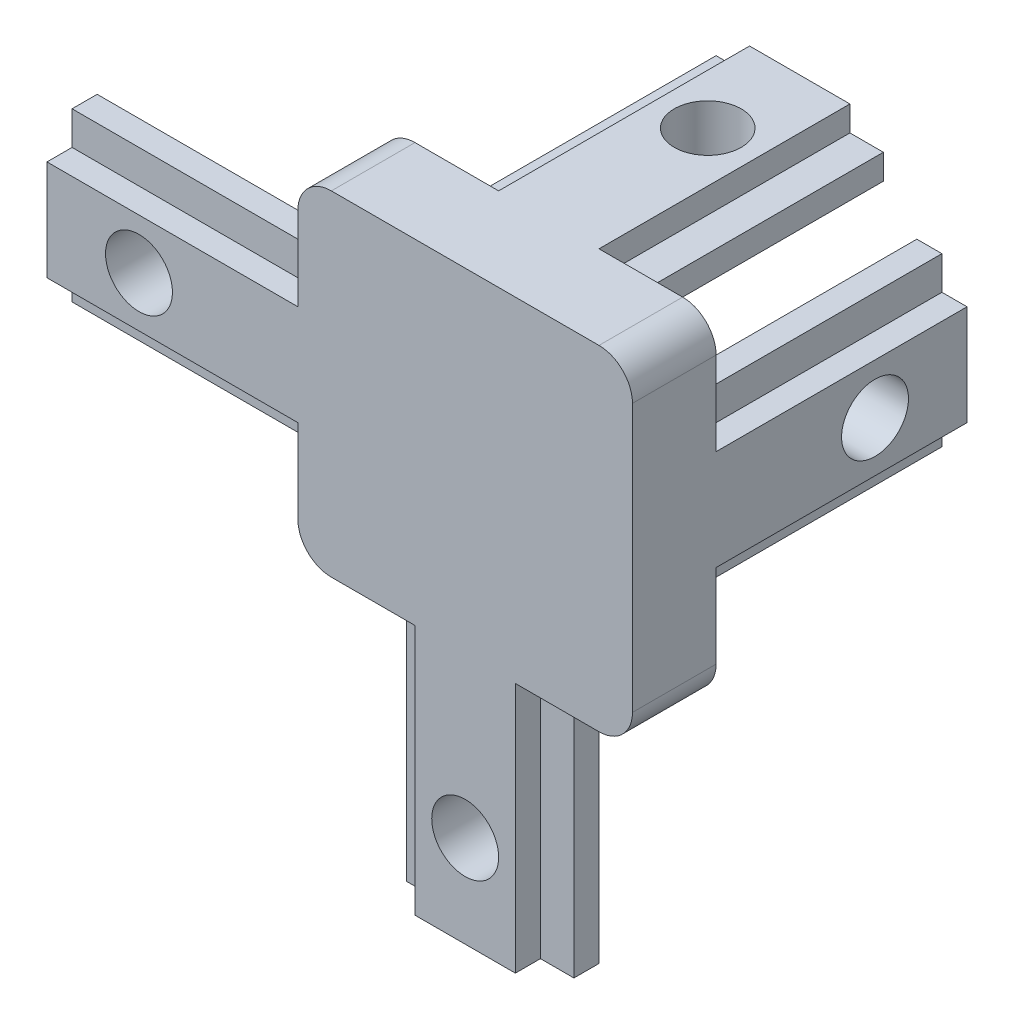
from build123d import *

# Parameters (mm, degrees)
SKETCH1_W                 = 35.000000224
SKETCH1_H                 = 10
BOSS_EXTRUDE1_DEPTH       = 5
CUT_EXTRUDE1_DEPTH        = 15.000000224
SKETCH3_W                 = 20
SKETCH3_H                 = 5
BOSS_EXTRUDE2_DEPTH       = 5
CUT_EXTRUDE2_DEPTH        = 15.000000224
SKETCH5_W                 = 20
SKETCH5_H                 = 5
BOSS_EXTRUDE3_DEPTH       = 5
BOSS_EXTRUDE4_DEPTH       = 15
BOSS_EXTRUDE5_DEPTH       = 15
BOSS_EXTRUDE6_DEPTH       = 15
CUT_EXTRUDE3_DEPTH        = 1
SKETCH10_W                = 15
SKETCH10_H                = 1.5
CUT_EXTRUDE4_DEPTH        = 2.000000104
SKETCH11_W                = 2.000000194
SKETCH11_H                = 1.5
CUT_EXTRUDE5_DEPTH        = 15
SKETCH12_W                = 1.5
SKETCH12_H                = 2
CUT_EXTRUDE6_DEPTH        = 15.000000224
SKETCH13_W                = 1.5
SKETCH13_H                = 2.000000104
CUT_EXTRUDE7_DEPTH        = 15.000000224
SKETCH14_W                = 1.999999806
SKETCH14_H                = 1.5
CUT_EXTRUDE8_DEPTH        = 15
SKETCH15_W                = 1.5
SKETCH15_H                = 15
CUT_EXTRUDE9_DEPTH        = 2.000000104
SKETCH16_W                = 1.5
SKETCH16_H                = 15
CUT_EXTRUDE10_DEPTH       = 2
SKETCH17_W                = 1.999999806
SKETCH17_H                = 1.5
CUT_EXTRUDE11_DEPTH       = 15
F_6_CLEARANCE_HOLE1_D     = 4
F_6_CLEARANCE_HOLE1_DEPTH = 5
F_6_CLEARANCE_HOLE2_D     = 4
F_6_CLEARANCE_HOLE2_DEPTH = 35
F_6_CLEARANCE_HOLE3_D     = 4
F_6_CLEARANCE_HOLE3_DEPTH = 35.000000224
FILLET1_R                 = 2


with BuildPart() as part:
    # Sketch1 → Boss-Extrude1 (new body)
    with BuildSketch(Plane(origin=(0, 0, -5), x_dir=(-1, 0, 0), z_dir=(0, 0, -1))):
        with Locations((-2.499999888, 10)):
            Rectangle(SKETCH1_W, SKETCH1_H)
    extrude(amount=-BOSS_EXTRUDE1_DEPTH)

    # Sketch2 → Cut-Extrude1 (cut)
    with BuildSketch(Plane.ZY.offset(15.000000224)):
        Polygon((-3, 5), (-5, 7), (-5, 5), align=None)
    extrude(amount=-CUT_EXTRUDE1_DEPTH, mode=Mode.SUBTRACT)

    # Sketch3 → Boss-Extrude2 (add)
    with BuildSketch(Plane.XZ.offset(-5)):
        with Locations((10, -2.5)):
            Rectangle(SKETCH3_W, SKETCH3_H)
    extrude(amount=BOSS_EXTRUDE2_DEPTH)

    # Sketch4 → Cut-Extrude2 (cut)
    with BuildSketch(Plane.ZY.offset(15.000000224)):
        Polygon((-5, 13), (-3, 15), (-5, 15), align=None)
    extrude(amount=-CUT_EXTRUDE2_DEPTH, mode=Mode.SUBTRACT)

    # Sketch5 → Boss-Extrude3 (add)
    with BuildSketch(Plane(origin=(0, 15, 0), x_dir=(-1, 0, 0), z_dir=(0, 1, 0))):
        with Locations((-10, -2.5)):
            Rectangle(SKETCH5_W, SKETCH5_H)
    extrude(amount=BOSS_EXTRUDE3_DEPTH)

    # Sketch6 → Boss-Extrude4 (add)
    with BuildSketch(Plane.XZ):
        Polygon((15, 0), (15, -3), (13, -5), (7, -5), (5, -3), (5, 0), align=None)
    extrude(amount=BOSS_EXTRUDE4_DEPTH)

    # Sketch7 → Boss-Extrude5 (add)
    with BuildSketch(Plane(origin=(0, 0, -5), x_dir=(-1, 0, 0), z_dir=(0, 0, -1))):
        Polygon((-5, 20), (-5, 17), (-7, 15), (-13, 15), (-15, 17), (-15, 20), align=None)
    extrude(amount=BOSS_EXTRUDE5_DEPTH)

    # Sketch8 → Boss-Extrude6 (add)
    with BuildSketch(Plane(origin=(0, 0, -5), x_dir=(-1, 0, 0), z_dir=(0, 0, -1))):
        Polygon((-20, 5), (-20, 15), (-17, 15), (-15, 13), (-15, 7), (-17, 5), align=None)
    extrude(amount=BOSS_EXTRUDE6_DEPTH)

    # Sketch9 → Cut-Extrude3 (cut)
    with BuildSketch(Plane(origin=(0, 0, -5), x_dir=(-1, 0, 0), z_dir=(0, 0, -1))):
        Polygon((-16.000000238, 16), (-16.000000238, 14.000000238), (-15, 13), (-15, 7), (-16.000000238, 5.999999762), (-16.000000238, 4), (-4, 4), (-4, 16), (-6, 16), (-7, 15), (-13, 15), (-14, 16), align=None)
    extrude(amount=-CUT_EXTRUDE3_DEPTH, mode=Mode.SUBTRACT)

    # Sketch10 → Cut-Extrude4 (cut)
    with BuildSketch(Plane.ZY.offset(-5)):
        with Locations((-12.5, 19.25)):
            Rectangle(SKETCH10_W, SKETCH10_H)
    extrude(amount=-CUT_EXTRUDE4_DEPTH, mode=Mode.SUBTRACT)

    # Sketch11 → Cut-Extrude5 (cut)
    with BuildSketch(Plane.XZ.offset(15)):
        with Locations((6.000000097, -0.75)):
            Rectangle(SKETCH11_W, SKETCH11_H)
    extrude(amount=-CUT_EXTRUDE5_DEPTH, mode=Mode.SUBTRACT)

    # Sketch12 → Cut-Extrude6 (cut)
    with BuildSketch(Plane.ZY.offset(15.000000224)):
        with Locations((-0.75, 14)):
            Rectangle(SKETCH12_W, SKETCH12_H)
    extrude(amount=-CUT_EXTRUDE6_DEPTH, mode=Mode.SUBTRACT)

    # Sketch13 → Cut-Extrude7 (cut)
    with BuildSketch(Plane.ZY.offset(15.000000224)):
        with Locations((-0.75, 6.000000052)):
            Rectangle(SKETCH13_W, SKETCH13_H)
    extrude(amount=-CUT_EXTRUDE7_DEPTH, mode=Mode.SUBTRACT)

    # Sketch14 → Cut-Extrude8 (cut)
    with BuildSketch(Plane.XZ.offset(15)):
        with Locations((14.000000097, -0.75)):
            Rectangle(SKETCH14_W, SKETCH14_H)
    extrude(amount=-CUT_EXTRUDE8_DEPTH, mode=Mode.SUBTRACT)

    # Sketch15 → Cut-Extrude9 (cut)
    with BuildSketch(Plane.XZ.offset(-5)):
        with Locations((19.25, -12.5)):
            Rectangle(SKETCH15_W, SKETCH15_H)
    extrude(amount=-CUT_EXTRUDE9_DEPTH, mode=Mode.SUBTRACT)

    # Sketch16 → Cut-Extrude10 (cut)
    with BuildSketch(Plane(origin=(0, 15, 0), x_dir=(-1, 0, 0), z_dir=(0, 1, 0))):
        with Locations((-19.25, -12.5)):
            Rectangle(SKETCH16_W, SKETCH16_H)
    extrude(amount=-CUT_EXTRUDE10_DEPTH, mode=Mode.SUBTRACT)

    # Sketch17 → Cut-Extrude11 (cut)
    with BuildSketch(Plane(origin=(0, 0, -20), x_dir=(-1, 0, 0), z_dir=(0, 0, -1))):
        with Locations((-14.000000097, 19.25)):
            Rectangle(SKETCH17_W, SKETCH17_H)
    extrude(amount=-CUT_EXTRUDE11_DEPTH, mode=Mode.SUBTRACT)

    # #6 Clearance Hole1
    with Locations(Plane(origin=(0, 0, -5), x_dir=(-1, 0, 0), z_dir=(0, 0, -1))):
        with Locations((-10, -9.5), (9.5, 10)):
            Hole(F_6_CLEARANCE_HOLE1_D / 2, depth=F_6_CLEARANCE_HOLE1_DEPTH)

    # #6 Clearance Hole2
    with Locations(Plane(origin=(0, 20, 0), x_dir=(1, 0, 0), z_dir=(0, 1, 0))):
        with Locations((10.000000149, 14.5)):
            Hole(F_6_CLEARANCE_HOLE2_D / 2, depth=F_6_CLEARANCE_HOLE2_DEPTH)

    # #6 Clearance Hole3
    with Locations(Plane(origin=(20, 0, 0), x_dir=(0, 0, -1), z_dir=(1, 0, 0))):
        with Locations((14.5, 10.000000052)):
            Hole(F_6_CLEARANCE_HOLE3_D / 2, depth=F_6_CLEARANCE_HOLE3_DEPTH)

    # Fillet1
    fillet1_edges = [part.edges().sort_by_distance(p)[0] for p in [
        (20, 0, -2.5),
        (0, 0, -2.5),
        (0, 20, -2.5),
        (20, 20, -2.5),
    ]]
    fillet(fillet1_edges, radius=FILLET1_R)


solid = part.part
